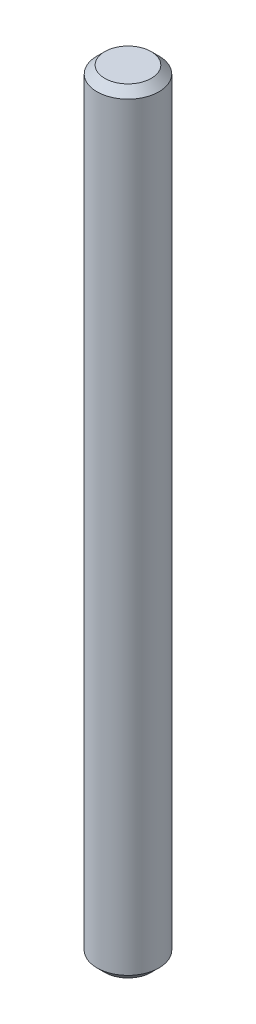
from build123d import *

# Parameters (mm, degrees)
SKETCH1_R           = 4
BOSS_EXTRUDE1_DEPTH = 100
CHAMFER1_SIZE       = 1


with BuildPart() as part:
    # Sketch1 → Boss-Extrude1 (new body)
    with BuildSketch(Plane(origin=(0, 0, 0), x_dir=(1, 0, 0), z_dir=(0, 1, 0))):
        Circle(SKETCH1_R)
    extrude(amount=BOSS_EXTRUDE1_DEPTH)

    # Chamfer1
    chamfer1_edges = [part.edges().sort_by_distance(p)[0] for p in [
        (-4, 0, 0),
        (-4, 100, 0),
    ]]
    chamfer(chamfer1_edges, length=CHAMFER1_SIZE)


solid = part.part
